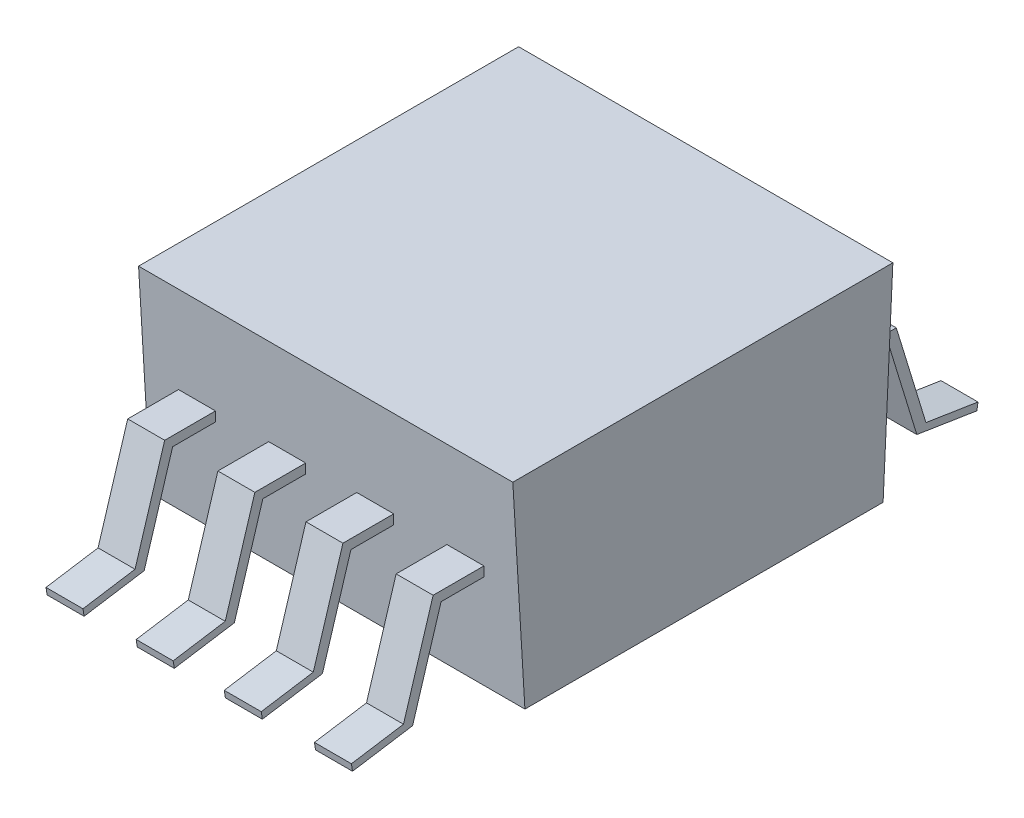
from build123d import *

# Parameters (mm, degrees)
EXTRUDE2_DEPTH      = 5.3975
EXTRUDE2_2_DEPTH    = 5.3975
SKETCH5_OUTSIDE_W   = 17.054
SKETCH5_OUTSIDE_H   = 24.332
SKETCH5_OUTSIDE_W_2 = 1.0668
SKETCH5_OUTSIDE_H_2 = 3.821737789
EXTRUDE3_DEPTH      = 4.235451139
EXTRUDE1_DEPTH      = 5.3975


with BuildPart() as part:
    # Sketch4 → Extrude2 (new body, symmetric)
    with BuildSketch(Plane(origin=(0, 0, 0), x_dir=(0, 0, -1), z_dir=(1, 0, 0))):
        Polygon((-5.19804058, 2.899559181), (-6.449967698, 2.899559181), (-7.271937219, 0.212691069), (-9.00398363, -0.060143282), (-9.0362215, 0.144513818), (-7.534579159, 0.381054601), (-6.679758262, 3.175307857), (-5.214483711, 3.175307857), align=None)
    extrude(amount=EXTRUDE2_DEPTH, both=True)


with BuildPart() as body_2:
    # Sketch4 → Extrude2 2 (new body, symmetric)
    with BuildSketch(Plane(origin=(0, 0, 0), x_dir=(0, 0, -1), z_dir=(1, 0, 0))):
        Polygon((5.214483711, 3.175307857), (5.19804058, 2.899559181), (6.449967698, 2.899559181), (7.271937219, 0.212691069), (9.00398363, -0.060143282), (9.0362215, 0.144513818), (7.534579159, 0.381054601), (6.679758262, 3.175307857), align=None)
    extrude(amount=EXTRUDE2_2_DEPTH, both=True)


with BuildPart() as extrude3_tool:
    # Sketch5 outside → Extrude3 (new body, through all)
    with BuildSketch(Plane(origin=(0, 3.175307857, 0), x_dir=(1, 0, 0), z_dir=(0, 1, 0))):
        Rectangle(SKETCH5_OUTSIDE_W, SKETCH5_OUTSIDE_H)
        with Locations((-3.871213345, -7.125352605)):
            Rectangle(SKETCH5_OUTSIDE_W_2, SKETCH5_OUTSIDE_H_2, mode=Mode.SUBTRACT)
        with Locations((-1.27, -7.125352605)):
            Rectangle(SKETCH5_OUTSIDE_W_2, SKETCH5_OUTSIDE_H_2, mode=Mode.SUBTRACT)
        with Locations((3.871213345, -7.125352605)):
            Rectangle(SKETCH5_OUTSIDE_W_2, SKETCH5_OUTSIDE_H_2, mode=Mode.SUBTRACT)
        with Locations((1.27, -7.125352605)):
            Rectangle(SKETCH5_OUTSIDE_W_2, SKETCH5_OUTSIDE_H_2, mode=Mode.SUBTRACT)
        with Locations((-3.871213345, 7.125352605)):
            Rectangle(SKETCH5_OUTSIDE_W_2, SKETCH5_OUTSIDE_H_2, mode=Mode.SUBTRACT)
        with Locations((-1.27, 7.125352605)):
            Rectangle(SKETCH5_OUTSIDE_W_2, SKETCH5_OUTSIDE_H_2, mode=Mode.SUBTRACT)
        with Locations((1.27, 7.125352605)):
            Rectangle(SKETCH5_OUTSIDE_W_2, SKETCH5_OUTSIDE_H_2, mode=Mode.SUBTRACT)
        with Locations((3.871213345, 7.125352605)):
            Rectangle(SKETCH5_OUTSIDE_W_2, SKETCH5_OUTSIDE_H_2, mode=Mode.SUBTRACT)
    extrude(amount=-EXTRUDE3_DEPTH)


with BuildPart() as part_1:
    add(part.part)

    # Extrude3: cut by extrude3_tool
    add(extrude3_tool.part, mode=Mode.SUBTRACT)



with BuildPart() as body_2_1:
    add(body_2.part)

    # Extrude3: cut by extrude3_tool
    add(extrude3_tool.part, mode=Mode.SUBTRACT)


with BuildPart() as part_2:
    add(part_1.part)

    add(body_2_1.part)  # Extrude1 merges body 2
    # Sketch2 → Extrude1 (add, symmetric)
    with BuildSketch(Plane(origin=(0, 0, 0), x_dir=(0, 0, -1), z_dir=(1, 0, 0))):
        Polygon((5.587899815, 5.842), (-5.37350086, 5.842), (-5.02513737, 0), (5.306040159, 0), align=None)
    extrude(amount=EXTRUDE1_DEPTH, both=True)


solid = part_2.part
